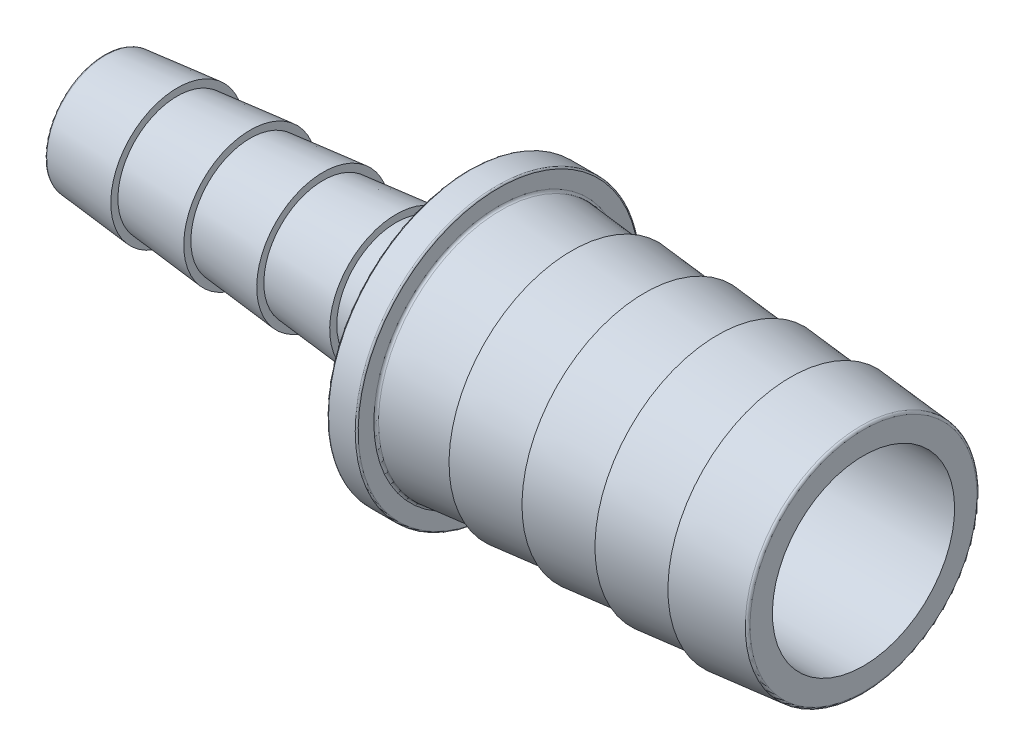
from build123d import *

# Parameters (mm, degrees)
LPATTERN1_COUNT = 4
LPATTERN1_PITCH = 4.88188
LPATTERN2_COUNT = 4
LPATTERN2_PITCH = 4.88188
FILLET1_R       = 0.09906
FILLET2_R       = 0.142875
FILLET3_R       = 0.1651


with BuildPart() as part:
    # Sketch2 → Revolve1 (revolve)
    with BuildSketch(Plane.XY, mode=Mode.PRIVATE) as revolve1_sk:
        Polygon((-25.4, 3.96875), (-5.87248, 3.96875), (-0.9906, 4.445), (-0.9906, 9.4996), (0.9906, 9.4996), (0.9906, 8.2042), (5.87248, 7.747), (25.4, 7.747), (25.4, 6.096), (0.9906, 6.096), (-0.9906, 2.54), (-25.4, 2.54), align=None)
    revolve(revolve1_sk.sketch.rotate(Axis((-25.4, 0, 0), (1, 0, 0)), 180), axis=Axis((-25.4, 0, 0), (1, 0, 0)))

    # Sketch3 → Revolve2 (revolve)
    with BuildSketch(Plane.XY, mode=Mode.PRIVATE) as revolve2_sk:
        Polygon((-25.4, 3.96875), (-20.51812, 3.96875), (-20.51812, 4.445), align=None)
    revolve2 = revolve(revolve2_sk.sketch.rotate(Axis((-25.4, 0, 0), (1, 0, 0)), 180), axis=Axis((-25.4, 0, 0), (1, 0, 0)))

    # LPattern1: Revolve2 ×4
    with Locations(*[(i * LPATTERN1_PITCH, 0, 0) for i in range(1, LPATTERN1_COUNT)]):
        add(revolve2)

    # Sketch4 → Revolve3 (revolve)
    with BuildSketch(Plane.XY, mode=Mode.PRIVATE) as revolve3_sk:
        Polygon((25.4, 7.747), (20.51812, 7.747), (20.51812, 8.2042), align=None)
    revolve3 = revolve(revolve3_sk.sketch.rotate(Axis((-25.4, 0, 0), (1, 0, 0)), 180), axis=Axis((-25.4, 0, 0), (1, 0, 0)))

    # LPattern2: Revolve3 ×4
    with Locations(*[(-i * LPATTERN2_PITCH, 0, 0) for i in range(1, LPATTERN2_COUNT)]):
        add(revolve3)

    # Fillet1
    fillet1_edges = [part.edges().sort_by_distance(p)[0] for p in [
        (0.9906, 9.4996, 0),
        (-0.9906, 9.4996, 0),
    ]]
    fillet(fillet1_edges, radius=FILLET1_R)

    # Fillet2
    fillet2_edges = [part.edges().sort_by_distance(p)[0] for p in [
        (-25.4, 3.96875, 0),
        (-0.9906, 4.445, 0),
    ]]
    fillet(fillet2_edges, radius=FILLET2_R)

    # Fillet3
    fillet3_edges = [part.edges().sort_by_distance(p)[0] for p in [
        (0.9906, 8.2042, 0),
        (25.4, 7.747, 0),
    ]]
    fillet(fillet3_edges, radius=FILLET3_R)


solid = part.part
